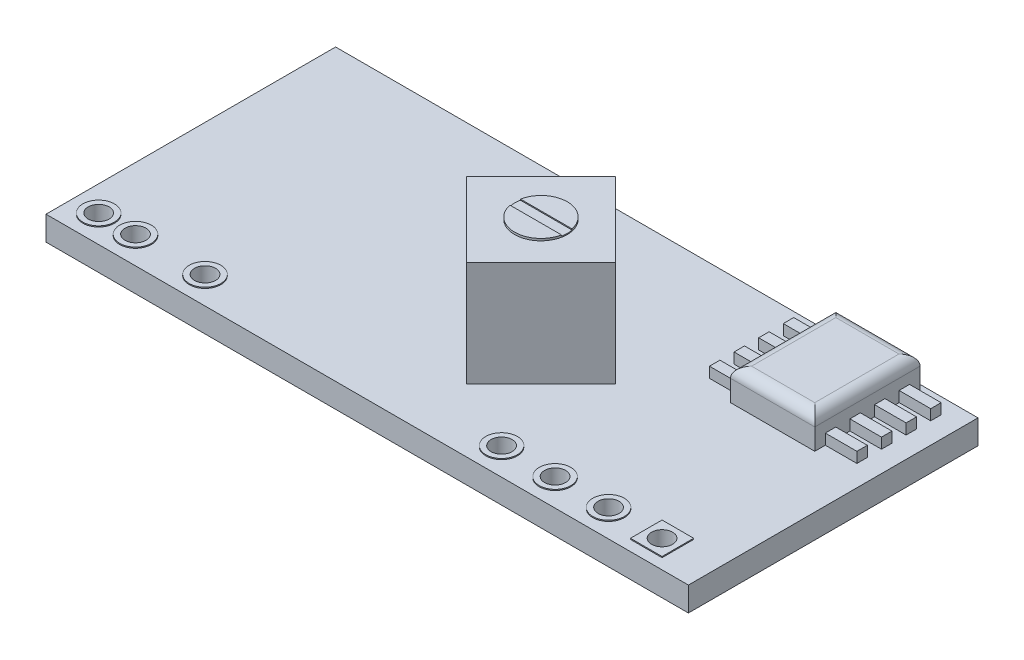
from build123d import *

# Parameters (mm, degrees)
SKETCH1_W           = 30.5
SKETCH1_H           = 13.75
BOSS_EXTRUDE2_DEPTH = 1.15
BOSS_EXTRUDE4_DEPTH = 5
BOSS_EXTRUDE5_DEPTH = 0.1
CUT_EXTRUDE1_DEPTH  = 0.05
SKETCH6_W           = 1.5
SKETCH6_H           = 0.75
BOSS_EXTRUDE6_DEPTH = 0.05
SKETCH7_R           = 0.5
CUT_EXTRUDE2_DEPTH  = 2.25
SKETCH8_W           = 4
SKETCH8_H           = 5
BOSS_EXTRUDE7_DEPTH = 1.5
FILLET1_R           = 0.5
SKETCH9_W           = 1.5
SKETCH9_H           = 0.495696311
BOSS_EXTRUDE8_DEPTH = 0.5


with BuildPart() as part:
    # Sketch1 → Boss-Extrude2 (new body)
    with BuildSketch(Plane(origin=(0, 0, 0), x_dir=(1, 0, 0), z_dir=(0, 1, 0))):
        with Locations((-7.383484163, -5.632918552)):
            Rectangle(SKETCH1_W, SKETCH1_H)
    extrude(amount=BOSS_EXTRUDE2_DEPTH)

    # Sketch3 → Boss-Extrude4 (add)
    with BuildSketch(Plane(origin=(0, 1.15, 0), x_dir=(1, 0, 0), z_dir=(0, 1, 0))):
        Polygon((-9.204551975, -5.972384646), (-5.669018069, -9.507918552), (-2.133484163, -5.972384646), (-5.669018069, -2.43685074), align=None)
    extrude(amount=BOSS_EXTRUDE4_DEPTH)

    # Sketch4 → Boss-Extrude5 (add)
    with BuildSketch(Plane(origin=(0, 6.15, 0), x_dir=(1, 0, 0), z_dir=(0, 1, 0))):
        with BuildLine():
            ThreePointArc((-6.919018069, -5.972384646), (-5.669018069, -7.222384646), (-4.419018069, -5.972384646))
            Line((-4.419018069, -5.972384646), (-6.919018069, -5.972384646))
        make_face()
        with BuildLine():
            Line((-6.919018069, -5.972384646), (-4.419018069, -5.972384646))
            ThreePointArc((-4.419018069, -5.972384646), (-5.669018069, -4.722384646), (-6.919018069, -5.972384646))
        make_face()
    extrude(amount=BOSS_EXTRUDE5_DEPTH)

    # Sketch5 → Cut-Extrude1 (cut)
    with BuildSketch(Plane(origin=(0, 6.25, 0), x_dir=(1, 0, 0), z_dir=(0, 1, 0))):
        with BuildLine():
            Line((-6.919018069, -5.972384646), (-4.419018069, -5.972384646))
            ThreePointArc((-4.419018069, -5.972384646), (-4.425347878, -5.846748444), (-4.444273197, -5.722384646))
            Line((-4.444273197, -5.722384646), (-6.89376294, -5.722384646))
            ThreePointArc((-6.89376294, -5.722384646), (-6.91268826, -5.846748444), (-6.919018069, -5.972384646))
        make_face()
        with BuildLine():
            ThreePointArc((-4.444273197, -6.222384646), (-4.425347878, -6.098020849), (-4.419018069, -5.972384646))
            Line((-4.419018069, -5.972384646), (-6.919018069, -5.972384646))
            ThreePointArc((-6.919018069, -5.972384646), (-6.91268826, -6.098020849), (-6.89376294, -6.222384646))
            Line((-6.89376294, -6.222384646), (-4.444273197, -6.222384646))
        make_face()
    extrude(amount=-CUT_EXTRUDE1_DEPTH, mode=Mode.SUBTRACT)

    # Sketch6 → Boss-Extrude6 (add)
    with BuildSketch(Plane(origin=(0, 1.15, 0), x_dir=(1, 0, 0), z_dir=(0, 1, 0))):
        with BuildLine():
            ThreePointArc((-3.003484163, -11.257918552), (-2.253484163, -12.007918552), (-1.503484163, -11.257918552))
            Line((-1.503484163, -11.257918552), (-3.003484163, -11.257918552))
        make_face()
        with BuildLine():
            Line((-3.003484163, -11.257918552), (-1.503484163, -11.257918552))
            ThreePointArc((-1.503484163, -11.257918552), (-2.253484163, -10.507918552), (-3.003484163, -11.257918552))
        make_face()
        with BuildLine():
            ThreePointArc((-0.463484163, -11.257918552), (0.286515837, -12.007918552), (1.036515837, -11.257918552))
            Line((1.036515837, -11.257918552), (-0.463484163, -11.257918552))
        make_face()
        with BuildLine():
            Line((-0.463484163, -11.257918552), (1.036515837, -11.257918552))
            ThreePointArc((1.036515837, -11.257918552), (0.286515837, -10.507918552), (-0.463484163, -11.257918552))
        make_face()
        with BuildLine():
            ThreePointArc((2.076515837, -11.257918552), (2.826515837, -12.007918552), (3.576515837, -11.257918552))
            Line((3.576515837, -11.257918552), (2.076515837, -11.257918552))
        make_face()
        with BuildLine():
            Line((2.076515837, -11.257918552), (3.576515837, -11.257918552))
            ThreePointArc((3.576515837, -11.257918552), (2.826515837, -10.507918552), (2.076515837, -11.257918552))
        make_face()
        with Locations((5.366515837, -10.882918552)):
            Rectangle(SKETCH6_W, SKETCH6_H)
        with Locations((5.366515837, -11.632918552)):
            Rectangle(SKETCH6_W, SKETCH6_H)
        with BuildLine():
            ThreePointArc((-17.083484163, -11.257918552), (-16.333484163, -12.007918552), (-15.583484163, -11.257918552))
            Line((-15.583484163, -11.257918552), (-17.083484163, -11.257918552))
        make_face()
        with BuildLine():
            Line((-17.083484163, -11.257918552), (-15.583484163, -11.257918552))
            ThreePointArc((-15.583484163, -11.257918552), (-16.333484163, -10.507918552), (-17.083484163, -11.257918552))
        make_face()
        with BuildLine():
            ThreePointArc((-20.383484163, -11.257918552), (-19.633484163, -12.007918552), (-18.883484163, -11.257918552))
            Line((-18.883484163, -11.257918552), (-20.383484163, -11.257918552))
        make_face()
        with BuildLine():
            Line((-20.383484163, -11.257918552), (-18.883484163, -11.257918552))
            ThreePointArc((-18.883484163, -11.257918552), (-19.633484163, -10.507918552), (-20.383484163, -11.257918552))
        make_face()
        with BuildLine():
            ThreePointArc((-22.133484163, -11.257918552), (-21.383484163, -12.007918552), (-20.633484163, -11.257918552))
            Line((-20.633484163, -11.257918552), (-22.133484163, -11.257918552))
        make_face()
        with BuildLine():
            Line((-22.133484163, -11.257918552), (-20.633484163, -11.257918552))
            ThreePointArc((-20.633484163, -11.257918552), (-21.383484163, -10.507918552), (-22.133484163, -11.257918552))
        make_face()
    boss_extrude6 = extrude(amount=BOSS_EXTRUDE6_DEPTH)

    # Mirror1: Boss-Extrude6 across plane
    add(boss_extrude6.mirror(Plane.ZX.offset(0.575)))

    # Sketch7 → Cut-Extrude2 (cut, through all)
    with BuildSketch(Plane(origin=(0, 1.2, 0), x_dir=(1, 0, 0), z_dir=(0, 1, 0))):
        with Locations((-21.383484163, -11.257918552)):
            Circle(SKETCH7_R)
        with Locations((-19.633484163, -11.257918552)):
            Circle(SKETCH7_R)
        with Locations((-16.333484163, -11.257918552)):
            Circle(SKETCH7_R)
        with Locations((-2.253484163, -11.257918552)):
            Circle(SKETCH7_R)
        with Locations((0.286515837, -11.257918552)):
            Circle(SKETCH7_R)
        with Locations((2.826515837, -11.257918552)):
            Circle(SKETCH7_R)
        with Locations((5.366515837, -11.257918552)):
            Circle(SKETCH7_R)
    extrude(amount=-CUT_EXTRUDE2_DEPTH, mode=Mode.SUBTRACT)

    # Sketch8 → Boss-Extrude7 (add)
    with BuildSketch(Plane(origin=(0, 1.15, 0), x_dir=(1, 0, 0), z_dir=(0, 1, 0))):
        with Locations((3.366515837, -1.507918552)):
            Rectangle(SKETCH8_W, SKETCH8_H)
    extrude(amount=BOSS_EXTRUDE7_DEPTH)

    # Fillet1
    fillet1_edges = [part.edges().sort_by_distance(p)[0] for p in [
        (5.366515837, 2.65, 1.507918552),
        (3.366515837, 2.65, -0.992081448),
        (1.366515837, 2.65, 1.507918552),
        (3.366515837, 2.65, 4.007918552),
    ]]
    fillet(fillet1_edges, radius=FILLET1_R)

    # Sketch9 → Boss-Extrude8 (add)
    with BuildSketch(Plane(origin=(0, 1.15, 0), x_dir=(1, 0, 0), z_dir=(0, 1, 0))):
        with Locations((6.116515837, -0.923867938)):
            Rectangle(SKETCH9_W, SKETCH9_H)
        with Locations((6.116515837, -2.091969167)):
            Rectangle(SKETCH9_W, SKETCH9_H)
        with Locations((6.116515837, -3.260070397)):
            Rectangle(SKETCH9_W, SKETCH9_H)
        with Locations((6.116515837, 0.244233293)):
            Rectangle(SKETCH9_W, SKETCH9_H)
        with Locations((0.616515837, -3.260070397)):
            Rectangle(SKETCH9_W, SKETCH9_H)
        with Locations((0.616515837, -2.091969167)):
            Rectangle(SKETCH9_W, SKETCH9_H)
        with Locations((0.616515837, -0.923867938)):
            Rectangle(SKETCH9_W, SKETCH9_H)
        with Locations((0.616515837, 0.244233293)):
            Rectangle(SKETCH9_W, SKETCH9_H)
    extrude(amount=BOSS_EXTRUDE8_DEPTH)


solid = part.part
